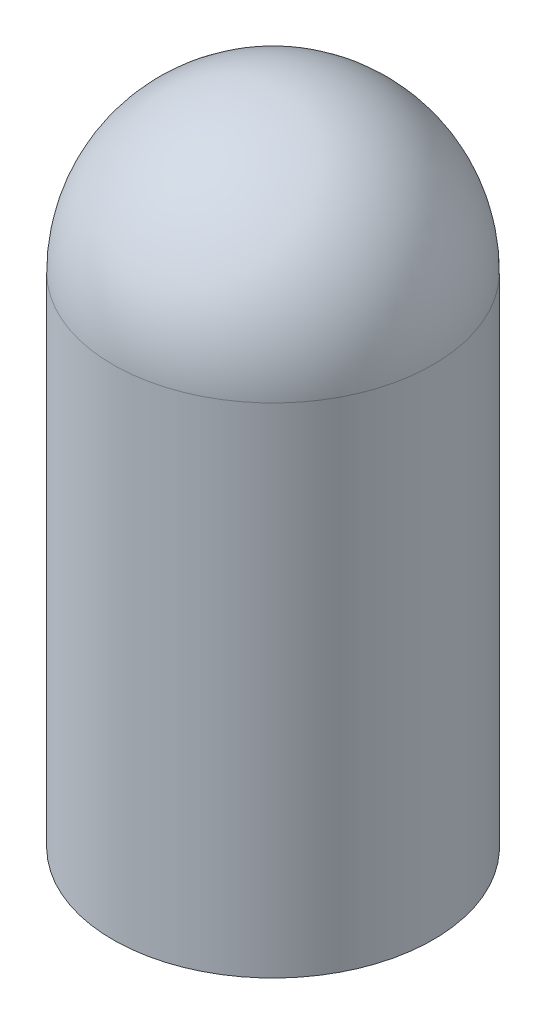
from build123d import *


with BuildPart() as part:
    # Sketch4 → Revolve4 (revolve)
    with BuildSketch(Plane.XY, mode=Mode.PRIVATE) as revolve4_sk:
        with BuildLine():
            ThreePointArc((2.5, 0), (1.767766953, 1.767766953), (0, 2.5))
            Line((0, 2.5), (0, -7.777777778))
            Line((0, -7.777777778), (2.5, -7.777777778))
            Line((2.5, -7.777777778), (2.5, 0))
        make_face()
    revolve(revolve4_sk.sketch.rotate(Axis((0, 2.5, 0), (0, -1, 0)), 180), axis=Axis((0, 2.5, 0), (0, -1, 0)))  # turned: the seam where the file's is


solid = part.part
